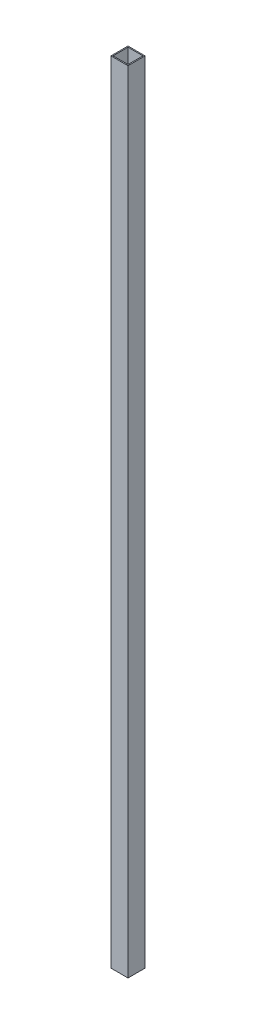
from build123d import *

# Parameters (mm, degrees)
SKETCH1_W           = 8
SKETCH1_H           = 8
SKETCH1_W_2         = 7
SKETCH1_H_2         = 7
BOSS_EXTRUDE1_DEPTH = 370


with BuildPart() as part:
    # Sketch1 → Boss-Extrude1 (new body)
    with BuildSketch(Plane(origin=(0, 0, 0), x_dir=(1, 0, 0), z_dir=(0, 1, 0))):
        with Locations((4, 4)):
            Rectangle(SKETCH1_W, SKETCH1_H)
        with Locations((4, 4)):
            Rectangle(SKETCH1_W_2, SKETCH1_H_2, mode=Mode.SUBTRACT)
    extrude(amount=BOSS_EXTRUDE1_DEPTH)


solid = part.part
